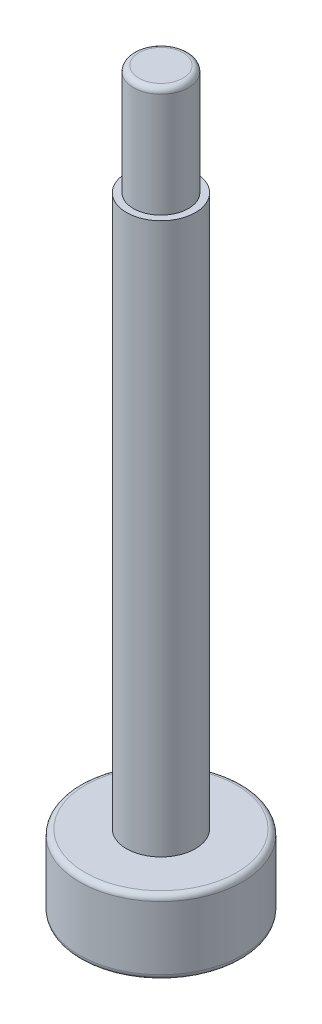
from build123d import *

# Parameters (mm, degrees)
SKETCH_1_R          = 2.95
EXTRUDE_1_DEPTH     = 2.7
SKETCH_2_R          = 1.25
EXTRUDE_2_DEPTH     = 20
SKETCH_3_R          = 1
EXTRUDE_3_DEPTH     = 4
CUT_EXTRUDE_1_DEPTH = 2
FILLET_1_R          = 0.2


with BuildPart() as part:
    # 草图1 → 凸台-拉伸1 (new body)
    with BuildSketch(Plane(origin=(0, 0, 0), x_dir=(1, 0, 0), z_dir=(0, 1, 0))):
        Circle(SKETCH_1_R)
    extrude(amount=EXTRUDE_1_DEPTH)

    # 草图2 → 凸台-拉伸2 (add)
    with BuildSketch(Plane(origin=(0, 2.7, 0), x_dir=(1, 0, 0), z_dir=(0, 1, 0))):
        Circle(SKETCH_2_R)
    extrude(amount=EXTRUDE_2_DEPTH)

    # 草图3 → 凸台-拉伸3 (add)
    with BuildSketch(Plane(origin=(0, 22.7, 0), x_dir=(1, 0, 0), z_dir=(0, 1, 0))):
        Circle(SKETCH_3_R)
    extrude(amount=EXTRUDE_3_DEPTH)

    # 草图4 → 切除-拉伸1 (cut)
    with BuildSketch(Plane.XZ):
        Polygon((2.247285488, -0.53201623), (1.584382314, 1.680198207), (-0.662903174, 2.212214437), (-2.247285488, 0.53201623), (-1.584382314, -1.680198207), (0.662903174, -2.212214437), align=None)
    extrude(amount=-CUT_EXTRUDE_1_DEPTH, mode=Mode.SUBTRACT)

    # 圆角1
    fillet_1_edges = [part.edges().sort_by_distance(p)[0] for p in [
        (-1, 26.7, 0),
        (-2.95, 0, 0),
        (-2.95, 2.7, 0),
    ]]
    fillet(fillet_1_edges, radius=FILLET_1_R)


solid = part.part
